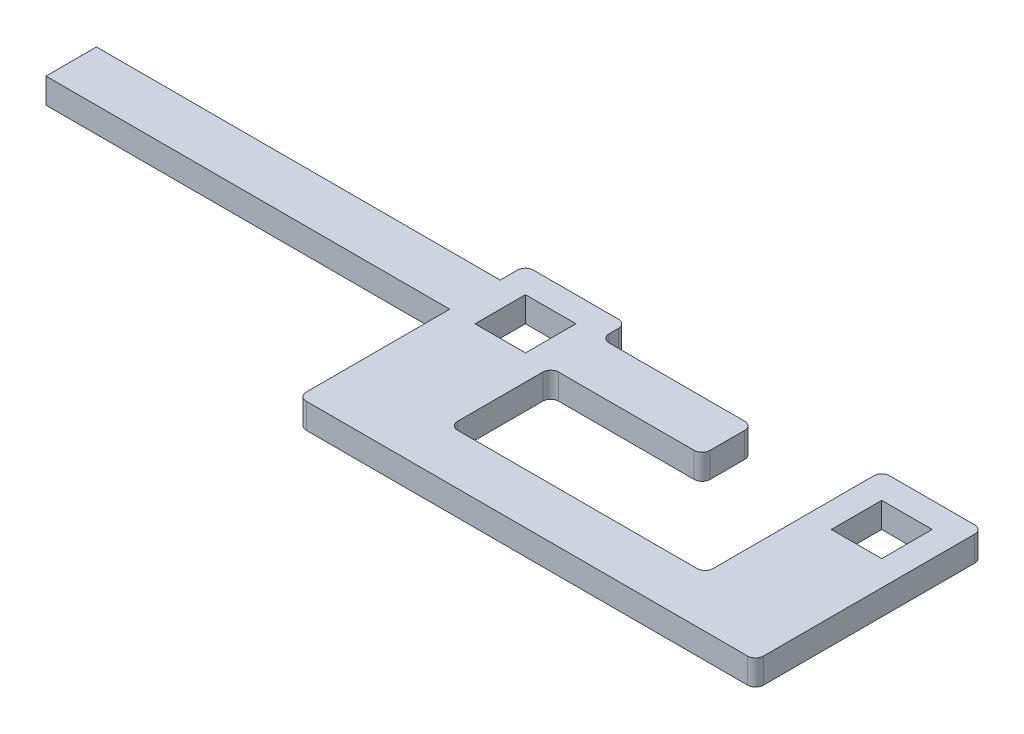
from build123d import *

# Parameters (mm, degrees)
SKETCH1_W              = 6.35
SKETCH1_H              = 6.35
ELASTIC_EXTRUDE_DEPTH  = 3.175
ELASTIC_CORNERFILLET_R = 1


with BuildPart() as part:
    # Sketch1 → Elastic_Extrude (new body)
    with BuildSketch(Plane(origin=(0, 0, 0), x_dir=(1, 0, 0), z_dir=(0, 1, 0))):
        Polygon((0, 0), (0, 19.05), (-50.8, 19.05), (-50.8, 25.4), (0, 25.4), (0, 28.575), (12.7, 28.575), (12.7, 25.4), (31.75, 25.4), (31.75, 19.05), (12.7, 19.05), (12.7, 6.35), (44.825000012, 6.35), (44.825000012, 28.575), (57.525000012, 28.575), (57.525000012, 0), (42.650000044, 0), (19.05, 0), align=None)
        with Locations((6.35, 22.225)):
            Rectangle(SKETCH1_W, SKETCH1_H, mode=Mode.SUBTRACT)
        with Locations((51.175000012, 22.225)):
            Rectangle(SKETCH1_W, SKETCH1_H, mode=Mode.SUBTRACT)
    extrude(amount=ELASTIC_EXTRUDE_DEPTH)

    # Elastic_CornerFillet
    elastic_cornerfillet_edges = [part.edges().sort_by_distance(p)[0] for p in [
        (0, 1.5875, 0),
        (0, 1.5875, -28.575),
        (12.7, 1.5875, -28.575),
        (12.7, 1.5875, -25.4),
        (31.75, 1.5875, -25.4),
        (31.75, 1.5875, -19.05),
        (12.7, 1.5875, -19.05),
        (12.7, 1.5875, -6.35),
        (44.825000012, 1.5875, -6.35),
        (44.825000012, 1.5875, -28.575),
        (57.525000012, 1.5875, -28.575),
        (57.525000012, 1.5875, 0),
    ]]
    fillet(elastic_cornerfillet_edges, radius=ELASTIC_CORNERFILLET_R)


solid = part.part
